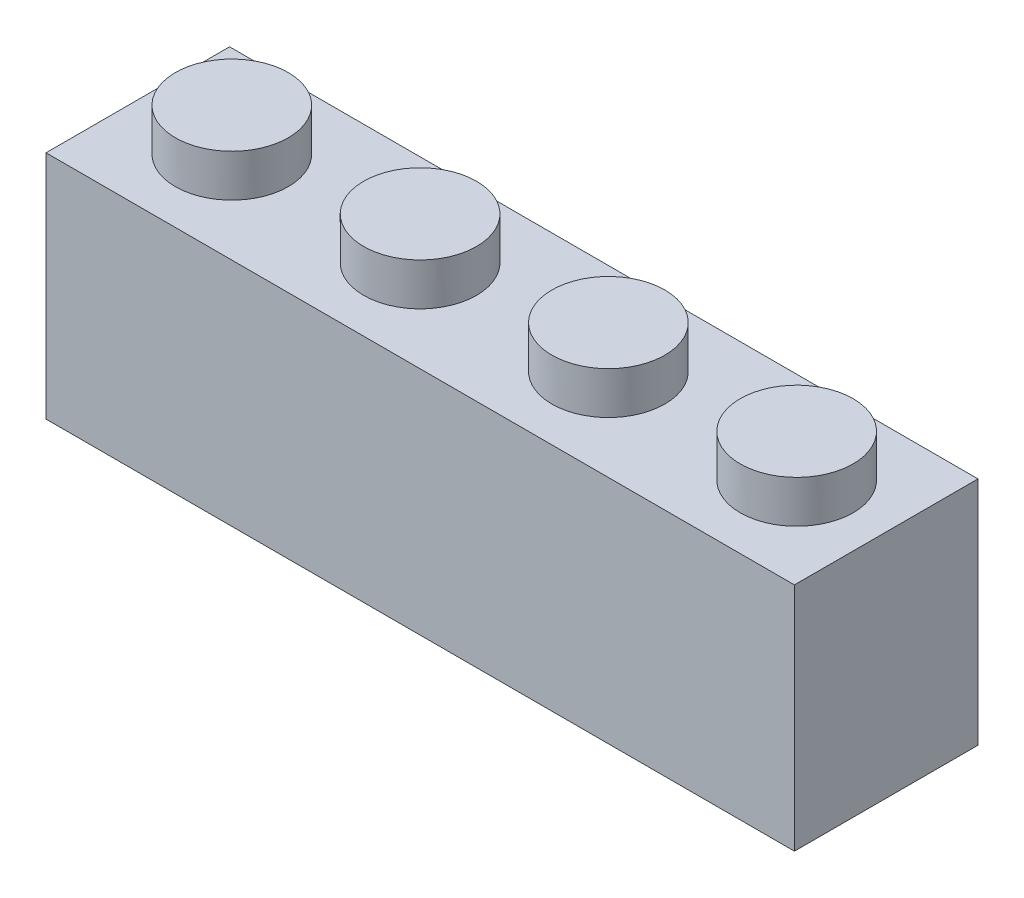
from build123d import *

# Parameters (mm, degrees)
SKETCH1_W           = 31.8
SKETCH1_H           = 7.8
BOSS_EXTRUDE1_DEPTH = 4.9
SKETCH2_R           = 2.4
BOSS_EXTRUDE2_DEPTH = 1.8
SKETCH3_W           = 28.6
SKETCH3_H           = 4.6
CUT_EXTRUDE1_DEPTH  = 8
SKETCH6_R           = 1.5
BOSS_EXTRUDE3_DEPTH = 8


with BuildPart() as part:
    # Sketch1 → Boss-Extrude1 (new body, symmetric)
    with BuildSketch(Plane(origin=(0, 0, 0), x_dir=(1, 0, 0), z_dir=(0, 1, 0))):
        Rectangle(SKETCH1_W, SKETCH1_H)
    extrude(amount=BOSS_EXTRUDE1_DEPTH, both=True)

    # Sketch2 → Boss-Extrude2 (add)
    with BuildSketch(Plane(origin=(15.9, 4.9, -3.9), x_dir=(1, 0, 0), z_dir=(0, -1, 0))):
        with Locations((-27.804807902, 3.9)):
            Circle(SKETCH2_R)
        with Locations((-19.804807902, 3.9)):
            Circle(SKETCH2_R)
        with Locations((-11.804807902, 3.9)):
            Circle(SKETCH2_R)
        with Locations((-3.804807902, 3.9)):
            Circle(SKETCH2_R)
    extrude(amount=-BOSS_EXTRUDE2_DEPTH)

    # Sketch3 → Cut-Extrude1 (cut)
    with BuildSketch(Plane.XZ.offset(4.9)):
        Rectangle(SKETCH3_W, SKETCH3_H)
    extrude(amount=-CUT_EXTRUDE1_DEPTH, mode=Mode.SUBTRACT)

    # Sketch6 → Boss-Extrude3 (add)
    with BuildSketch(Plane(origin=(15.9, 3.3, -3.9), x_dir=(-1, 0, 0), z_dir=(0, -1, 0))):
        with Locations((7.95, -3.9)):
            Circle(SKETCH6_R)
        with Locations((15.9, -3.9)):
            Circle(SKETCH6_R)
        with Locations((23.85, -3.9)):
            Circle(SKETCH6_R)
    extrude(amount=BOSS_EXTRUDE3_DEPTH)


solid = part.part
